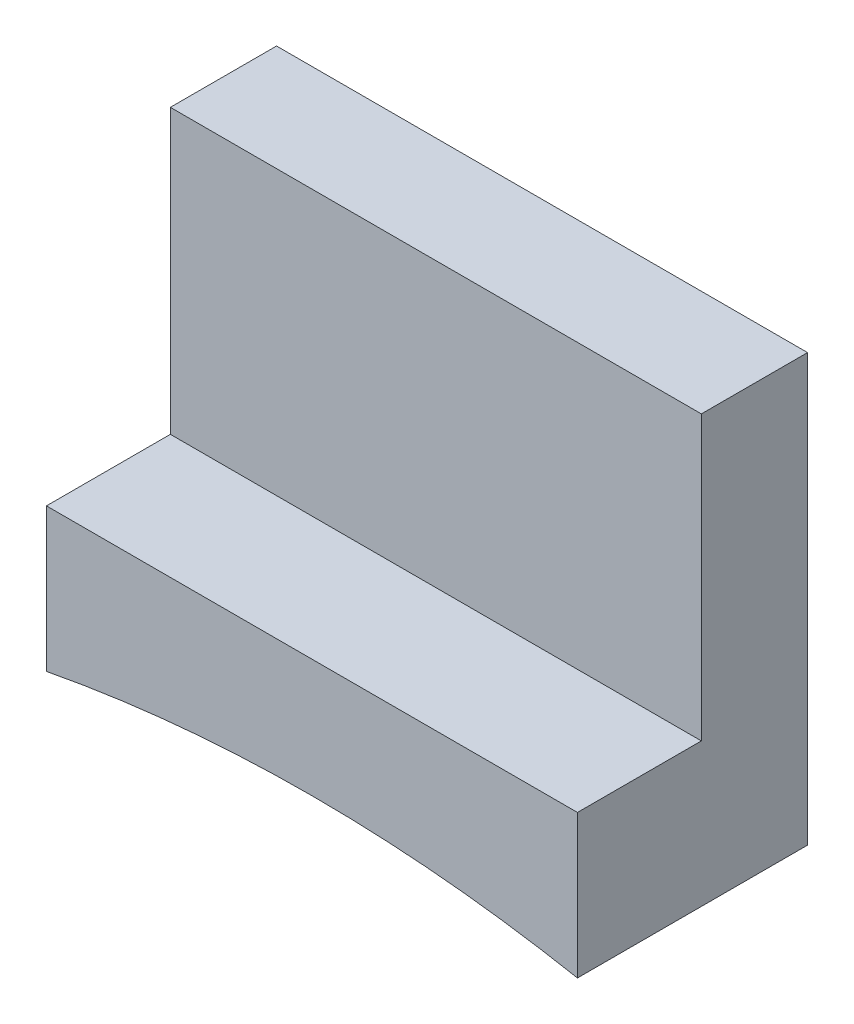
from build123d import *

# Parameters (mm, degrees)
SKETCH1_W           = 15
SKETCH1_H           = 6.5
BOSS_EXTRUDE1_DEPTH = 1
BOSS_EXTRUDE2_START = -6.5
BOSS_EXTRUDE2_DEPTH = 6.5
SKETCH3_W           = 15
SKETCH3_H           = 3
BOSS_EXTRUDE3_DEPTH = 8


with BuildPart() as part:
    # Sketch1 → Boss-Extrude1 (new body)
    with BuildSketch(Plane(origin=(0, 0, 0), x_dir=(1, 0, 0), z_dir=(0, 1, 0))):
        with Locations((7.5, 3.25)):
            Rectangle(SKETCH1_W, SKETCH1_H)
    extrude(amount=BOSS_EXTRUDE1_DEPTH)

    # Sketch2 → Boss-Extrude2 (add)
    with BuildSketch(Plane.XY.offset(BOSS_EXTRUDE2_START)):
        with BuildLine():
            Line((0, 0), (0, -3.050294479))
            ThreePointArc((0, -3.050294479), (7.5, -2.340878593), (15, -3.050294479))
            Line((15, -3.050294479), (15, 0))
            ThreePointArc((15, 0), (7.5, 0.659121407), (0, 0))
        make_face()
    extrude(amount=BOSS_EXTRUDE2_DEPTH)

    # Sketch3 → Boss-Extrude3 (add)
    with BuildSketch(Plane(origin=(0, 1, 0), x_dir=(1, 0, 0), z_dir=(0, 1, 0))):
        with Locations((7.5, 5)):
            Rectangle(SKETCH3_W, SKETCH3_H)
    extrude(amount=BOSS_EXTRUDE3_DEPTH)


solid = part.part
